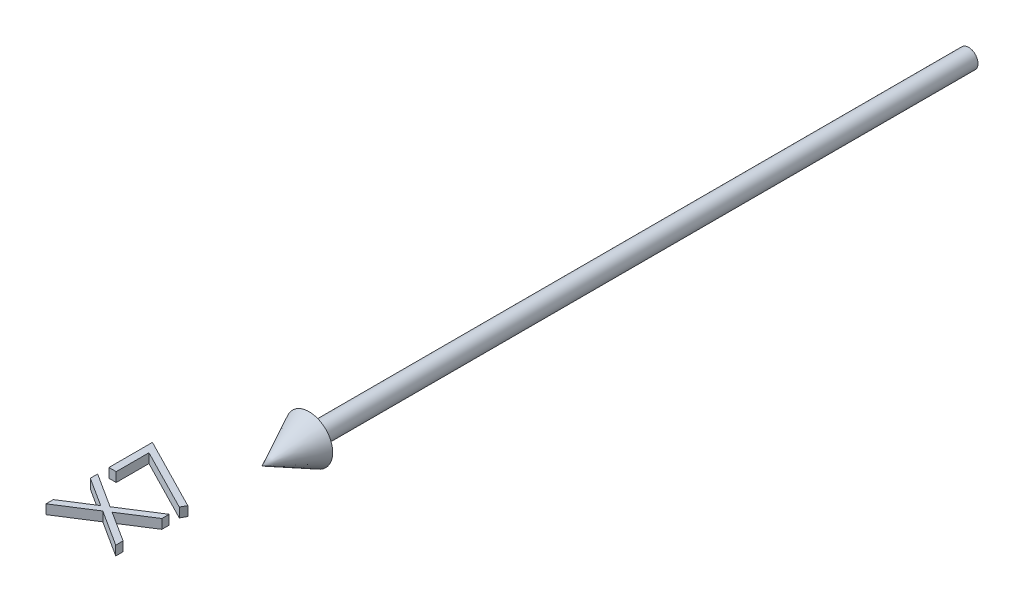
from build123d import *

# Parameters (mm, degrees)
BOSS_EXTRUDE1_DEPTH        = 1
BOSS_EXTRUDE1_DEPTH_BACK   = 1
BOSS_EXTRUDE1_2_DEPTH      = 1
BOSS_EXTRUDE1_2_DEPTH_BACK = 1


with BuildPart() as part:
    # Sketch2 → Revolve1 (revolve)
    with BuildSketch(Plane(origin=(0, 0, 0), x_dir=(1, 0, 0), z_dir=(0, 1, 0))):
        Polygon((0, -150), (5, -140), (2, -140), (2, 0), (0, 0), align=None)
    revolve(axis=Axis((0, 0, -41.949952025), (0, 0, 1)))


with BuildPart() as body_2:
    # Sketch3 → Boss-Extrude1 (new, two sides: drawn at the far end of the back side and taken through both)
    with BuildSketch(Plane(origin=(0, 0, 0), x_dir=(1, 0, 0), z_dir=(0, 1, 0)).offset(-BOSS_EXTRUDE1_DEPTH_BACK)):
        Polygon((-15, -167.5), (-15, -158.269230769), (0.384615385, -166.153846154), (-0.255408654, -167.316706731), (-13.461538462, -160.546875), (-13.461538462, -167.5), align=None)
    extrude(amount=BOSS_EXTRUDE1_DEPTH + BOSS_EXTRUDE1_DEPTH_BACK)


with BuildPart() as body_3:
    # Sketch3 → Boss-Extrude1 2 (new, two sides: drawn at the far end of the back side and taken through both)
    with BuildSketch(Plane(origin=(0, 0, 0), x_dir=(1, 0, 0), z_dir=(0, 1, 0)).offset(-BOSS_EXTRUDE1_2_DEPTH_BACK)):
        Polygon((-15, -180.865384615), (-15, -179.311899038), (-8.864182692, -175.384615385), (-15, -171.457331731), (-15, -169.903846154), (-7.650240385, -174.606370192), (0, -169.711538462), (0, -171.265024038), (-6.436298077, -175.384615385), (0, -179.504206731), (0, -181.057692308), (-7.650240385, -176.159855769), align=None)
    extrude(amount=BOSS_EXTRUDE1_2_DEPTH + BOSS_EXTRUDE1_2_DEPTH_BACK)


solid = Compound([part.part, body_2.part, body_3.part])
